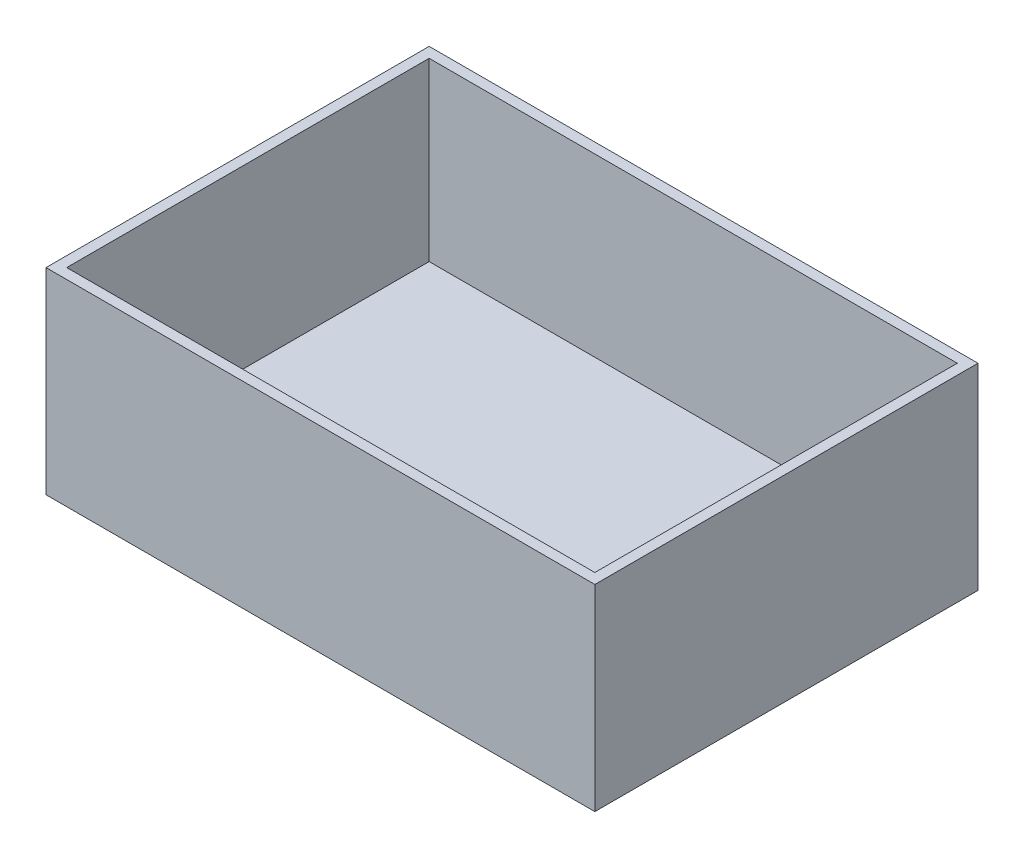
from build123d import *

# Parameters (mm, degrees)
SKETCH1_W           = 265
SKETCH1_H           = 185
BOSS_EXTRUDE1_DEPTH = 95
SKETCH2_W           = 255
SKETCH2_H           = 175
CUT_EXTRUDE1_DEPTH  = 85


with BuildPart() as part:
    # Sketch1 → Boss-Extrude1 (new body)
    with BuildSketch(Plane(origin=(0, 0, 0), x_dir=(1, 0, 0), z_dir=(0, 1, 0))):
        Rectangle(SKETCH1_W, SKETCH1_H)
    extrude(amount=BOSS_EXTRUDE1_DEPTH)

    # Sketch2 → Cut-Extrude1 (cut)
    with BuildSketch(Plane(origin=(0, 95, 0), x_dir=(1, 0, 0), z_dir=(0, 1, 0))):
        Rectangle(SKETCH2_W, SKETCH2_H)
    extrude(amount=-CUT_EXTRUDE1_DEPTH, mode=Mode.SUBTRACT)


solid = part.part
